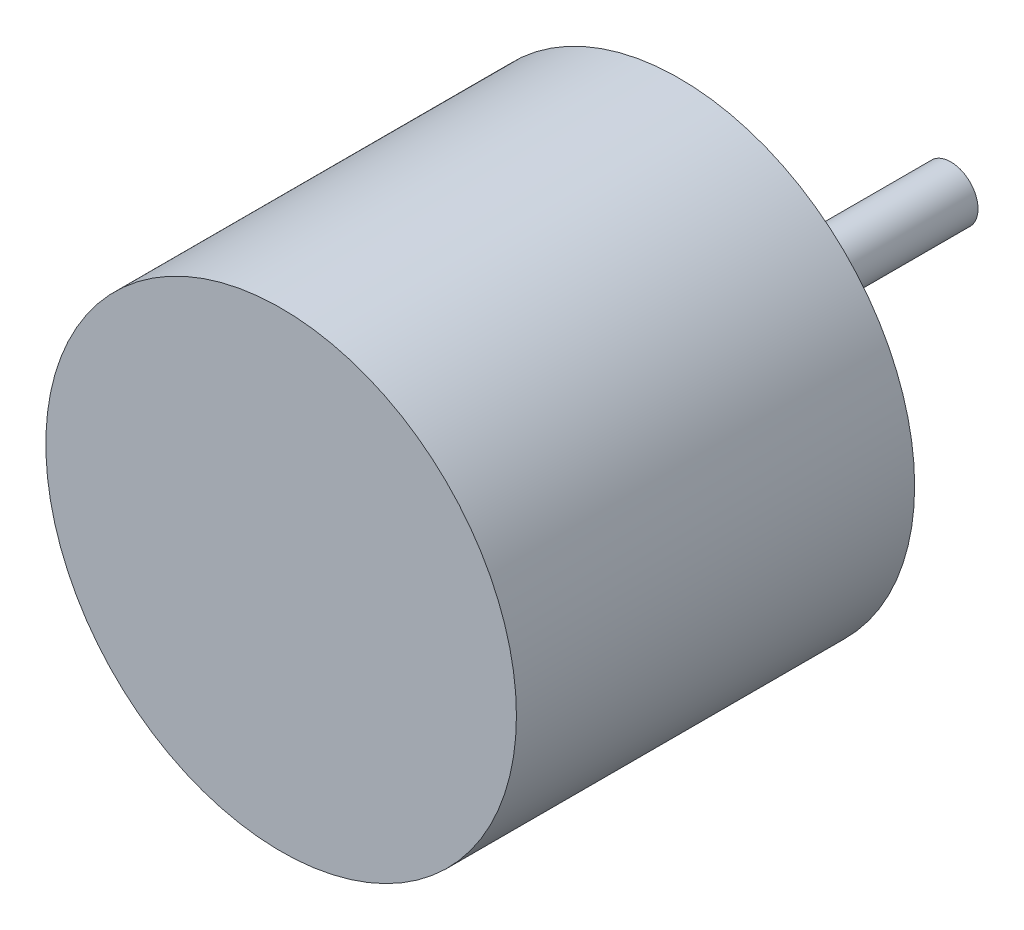
from build123d import *

# Parameters (mm, degrees)
ESQUISSE1_R        = 13
BOSS_EXTRU_1_DEPTH = 22
ESQUISSE2_R        = 1.5
BOSS_EXTRU_2_DEPTH = 15


with BuildPart() as part:
    # Esquisse1 → Boss.-Extru.1 (new body)
    with BuildSketch(Plane.XY):
        Circle(ESQUISSE1_R)
    extrude(amount=BOSS_EXTRU_1_DEPTH)

    # Esquisse2 → Boss.-Extru.2 (add)
    with BuildSketch(Plane(origin=(0, 0, 0), x_dir=(-1, 0, 0), z_dir=(0, 0, -1))):
        Circle(ESQUISSE2_R)
    extrude(amount=BOSS_EXTRU_2_DEPTH)


solid = part.part
